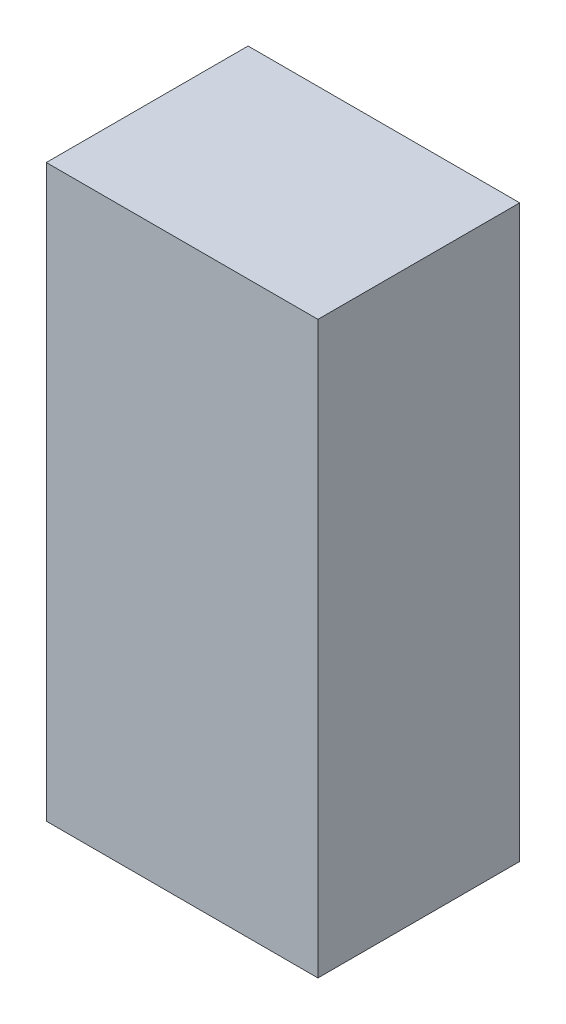
from build123d import *

# Parameters (mm, degrees)
CROQUIS1_W              = 35
CROQUIS1_H              = 26
SALIENTE_EXTRUIR1_DEPTH = 73.5


with BuildPart() as part:
    # Croquis1 → Saliente-Extruir1 (new body)
    with BuildSketch(Plane(origin=(0, 0, 0), x_dir=(1, 0, 0), z_dir=(0, 1, 0))):
        Rectangle(CROQUIS1_W, CROQUIS1_H)
    extrude(amount=SALIENTE_EXTRUIR1_DEPTH)


solid = part.part
